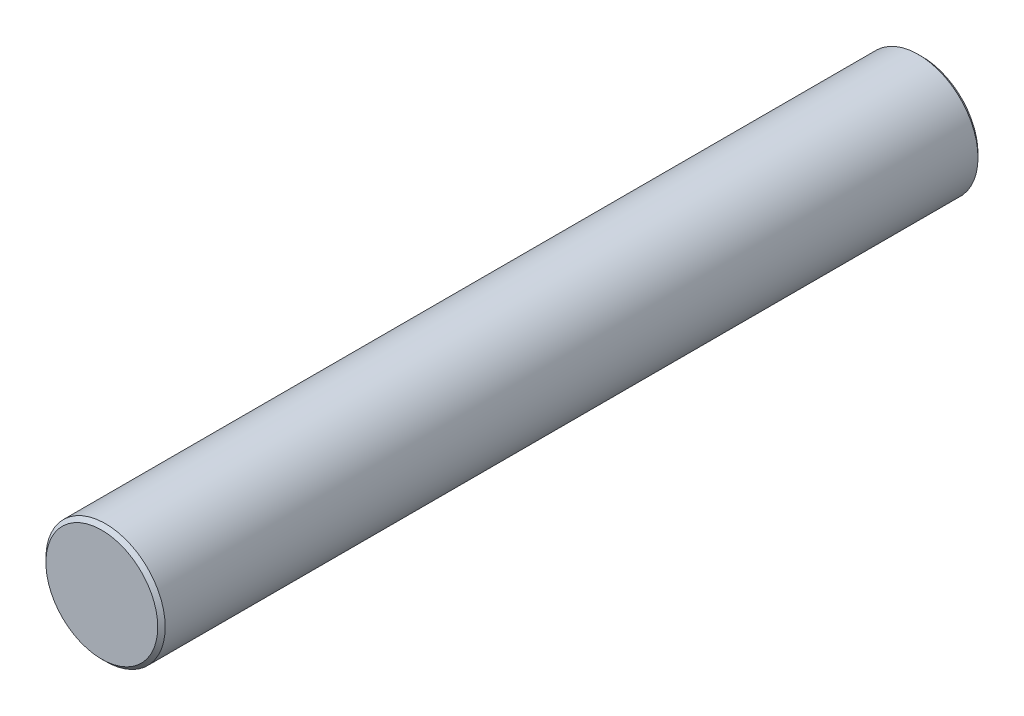
from build123d import *

# Parameters (mm, degrees)
SZKIC1_R                    = 8
DODANIE_WYCI_GNI_CIE1_DEPTH = 55
SFAZOWANIE1_SIZE            = 0.5
SZKIC2_R                    = 3
WYTNIJ_WYCI_GNI_CIE1_DEPTH  = 10
WYTNIJ_WYCI_GNI_CIE1_TAPER  = 5


with BuildPart() as part:
    # Szkic1 → Dodanie-wyciągnięcie1 (new body, symmetric)
    with BuildSketch(Plane.XY):
        with Locations((-33.610628805, 0)):
            Circle(SZKIC1_R)
    extrude(amount=DODANIE_WYCI_GNI_CIE1_DEPTH, both=True)

    # Sfazowanie1
    sfazowanie1_edges = [part.edges().sort_by_distance(p)[0] for p in [
        (-41.610628805, 0, -55),
        (-41.610628805, 0, 55),
    ]]
    chamfer(sfazowanie1_edges, length=SFAZOWANIE1_SIZE)

    # Szkic2 → Wytnij-wyciągnięcie1 (cut)
    with BuildSketch(Plane.ZY.offset(41.610628805)):
        with Locations((50.349966255, 0)):
            Circle(SZKIC2_R)
    extrude(amount=-WYTNIJ_WYCI_GNI_CIE1_DEPTH, taper=WYTNIJ_WYCI_GNI_CIE1_TAPER, mode=Mode.SUBTRACT)


solid = part.part
